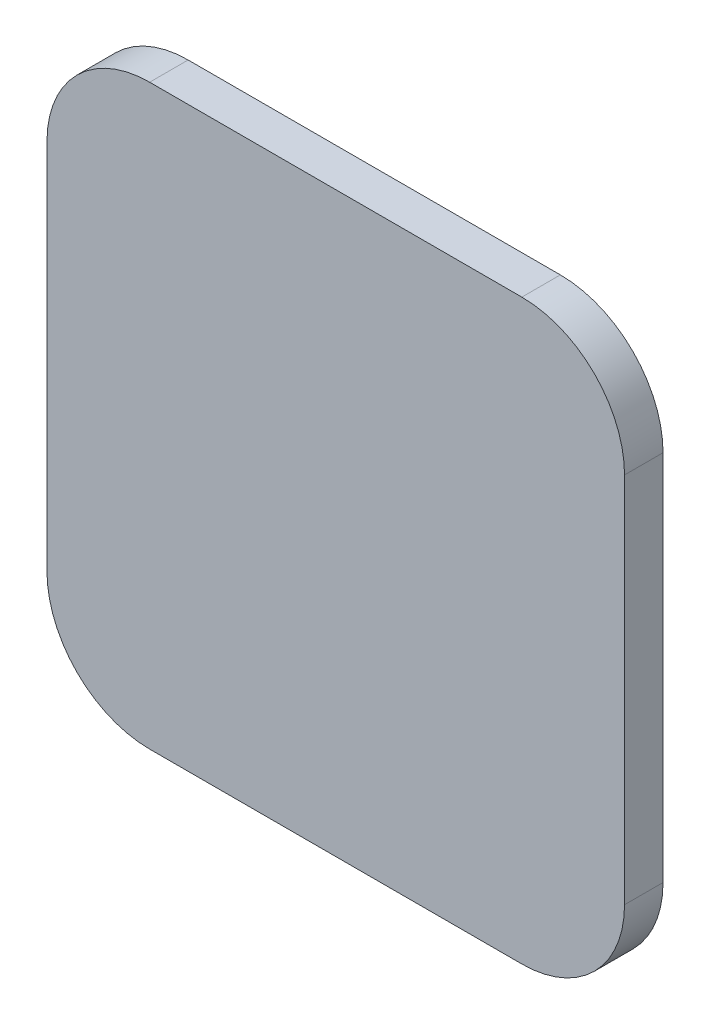
from build123d import *

# Parameters (mm, degrees)
BOSS_EXTRUDE1_DEPTH = 3


with BuildPart() as part:
    # Sketch1 → Boss-Extrude1 (new body)
    with BuildSketch(Plane.XY):
        with BuildLine():
            Line((1213.574821367, 135), (1242.574821367, 135))
            ThreePointArc((1242.574821367, 135), (1248.231675617, 137.343145751), (1250.574821367, 143))
            Line((1250.574821367, 143), (1250.574821367, 172))
            ThreePointArc((1250.574821367, 172), (1248.231675617, 177.656854249), (1242.574821367, 180))
            Line((1242.574821367, 180), (1213.574821367, 180))
            ThreePointArc((1213.574821367, 180), (1207.917967118, 177.656854249), (1205.574821367, 172))
            Line((1205.574821367, 172), (1205.574821367, 143))
            ThreePointArc((1205.574821367, 143), (1207.917967118, 137.343145751), (1213.574821367, 135))
        make_face()
    extrude(amount=-BOSS_EXTRUDE1_DEPTH)


solid = part.part
